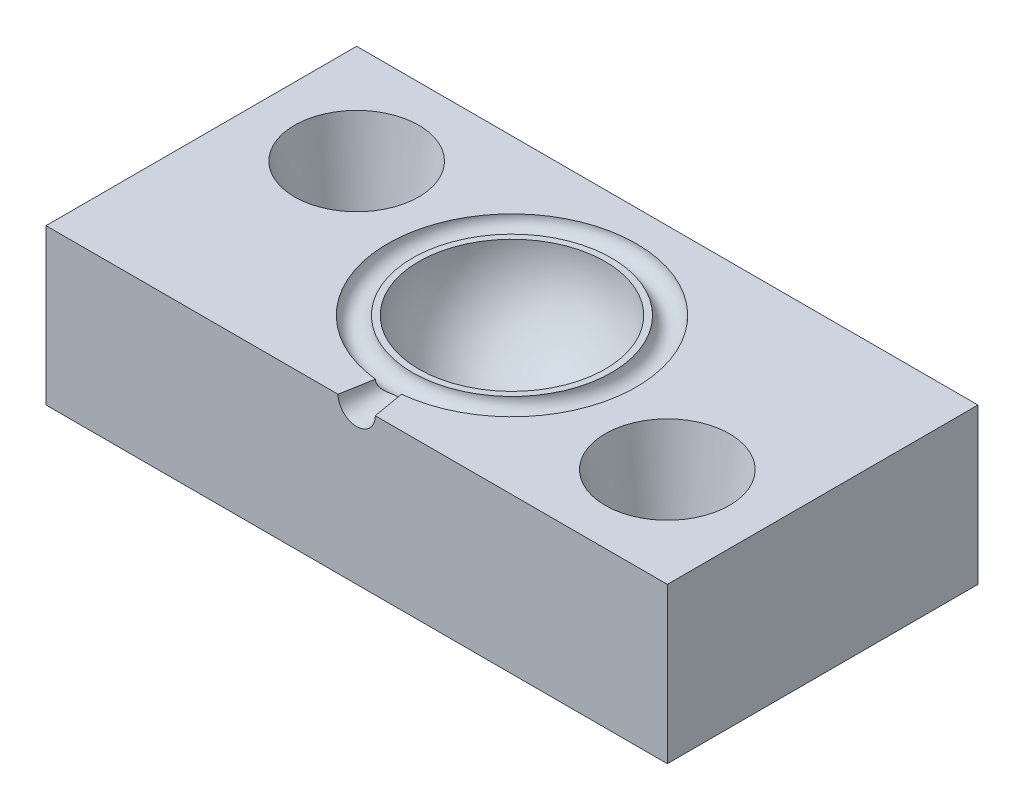
from build123d import *

# Parameters (mm, degrees)
ESQUISSE1_W                       = 50
ESQUISSE1_H                       = 25
BOSS_EXTRU_1_DEPTH                = 12.5
ESQUISSE2_R                       = 5
ENL_V_MAT_EXTRU_1_DEPTH           = 13.5
ENL_V_MAT_EXTRU_1_DRAFT           = -10
ENL_V_MAT_EXTRU_1_PROFILE_2_DEPTH = 13.5
ENL_V_MAT_EXTRU_1_PROFILE_2_DRAFT = -10
COQUE1_T                          = -3
ESQUISSE5_R                       = 1.5
ENL_V_MAT_EXTRU_2_DEPTH           = 4
ENL_V_MAT_EXTRU_2_DRAFT           = -10


with BuildPart() as part:
    # Esquisse1 → Boss.-Extru.1 (new body)
    with BuildSketch(Plane(origin=(0, 0, 0), x_dir=(1, 0, 0), z_dir=(0, 1, 0))):
        Rectangle(ESQUISSE1_W, ESQUISSE1_H)
    extrude(amount=BOSS_EXTRU_1_DEPTH)


with BuildPart() as enl_v_mat_extru_1_tool:
    # Esquisse2 → Enlèv. mat.-Extru.1 (with draft: the straight prism first)
    with BuildSketch(Plane(origin=(0, 12.5, 0), x_dir=(1, 0, 0), z_dir=(0, 1, 0))):
        with Locations((17, -4.5)):
            Circle(ESQUISSE2_R)
    extrude(amount=-ENL_V_MAT_EXTRU_1_DEPTH)
    # Enlèv. mat.-Extru.1: the draft: its side faces are tilted about the plane it starts from
    enl_v_mat_extru_1_sides = [enl_v_mat_extru_1_tool.faces().sort_by_distance(p)[0] for p in [
        (12, 5.75, 4.5),
    ]]
    draft(enl_v_mat_extru_1_sides, Plane(origin=(0, 12.5, 0), x_dir=(1, 0, 0), z_dir=(0, 1, 0)), ENL_V_MAT_EXTRU_1_DRAFT)


with BuildPart() as part_1:
    add(part.part)

    # Enlèv. mat.-Extru.1: cut by enl_v_mat_extru_1_tool
    add(enl_v_mat_extru_1_tool.part, mode=Mode.SUBTRACT)


with BuildPart() as enl_v_mat_extru_1_profile_2_tool:
    # Esquisse2 → Enlèv. mat.-Extru.1 profile 2 (with draft: the straight prism first)
    with BuildSketch(Plane(origin=(0, 12.5, 0), x_dir=(1, 0, 0), z_dir=(0, 1, 0))):
        with Locations((-17, 4.5)):
            Circle(ESQUISSE2_R)
    extrude(amount=-ENL_V_MAT_EXTRU_1_PROFILE_2_DEPTH)
    # Enlèv. mat.-Extru.1 profile 2: the draft: its side faces are tilted about the plane it starts from
    enl_v_mat_extru_1_profile_2_sides = [enl_v_mat_extru_1_profile_2_tool.faces().sort_by_distance(p)[0] for p in [
        (-22, 5.75, -4.5),
    ]]
    draft(enl_v_mat_extru_1_profile_2_sides, Plane(origin=(0, 12.5, 0), x_dir=(1, 0, 0), z_dir=(0, 1, 0)), ENL_V_MAT_EXTRU_1_PROFILE_2_DRAFT)


with BuildPart() as part_2:
    add(part_1.part)

    # Enlèv. mat.-Extru.1 profile 2: cut by enl_v_mat_extru_1_profile_2_tool
    add(enl_v_mat_extru_1_profile_2_tool.part, mode=Mode.SUBTRACT)

    # Esquisse3 → Enlèvement de matière-Révolution1 (revolve, cut)
    with BuildSketch(Plane.XY):
        with BuildLine():
            Line((0, 20), (0, 5))
            ThreePointArc((0, 5), (-7.5, 12.5), (0, 20))
        make_face()
    revolve(axis=Axis((0, 20, 0), (0, -1, 0)), mode=Mode.SUBTRACT)

    # Esquisse4 → Enlèvement de matière-Révolution3 (revolve, cut)
    with BuildSketch(Plane.XY, mode=Mode.PRIVATE) as enl_vement_de_mati_re_r_volution3_sk:
        with BuildLine():
            Line((8, 12.5), (10, 12.5))
            ThreePointArc((10, 12.5), (9, 11.5), (8, 12.5))
        make_face()
    revolve(enl_vement_de_mati_re_r_volution3_sk.sketch.rotate(Axis((0, 20, 0), (0, -1, 0)), 90), axis=Axis((0, 20, 0), (0, -1, 0)), mode=Mode.SUBTRACT)

    # Coque1
    coque1_openings = [part_2.faces().sort_by_distance(p)[0] for p in [
        (0, 0, 0),
    ]]
    offset(amount=COQUE1_T, openings=coque1_openings)


with BuildPart() as enl_v_mat_extru_2_tool:
    # Esquisse5 → Enlèv. mat.-Extru.2 (with draft: the straight prism first)
    with BuildSketch(Plane.XY.offset(12.5)):
        with Locations((0, 12.5)):
            Circle(ESQUISSE5_R)
    extrude(amount=-ENL_V_MAT_EXTRU_2_DEPTH)
    # Enlèv. mat.-Extru.2: the draft: its side faces are tilted about the plane it starts from
    enl_v_mat_extru_2_sides = [enl_v_mat_extru_2_tool.faces().sort_by_distance(p)[0] for p in [
        (-1.5, 12.5, 10.5),
    ]]
    draft(enl_v_mat_extru_2_sides, Plane.XY.offset(12.5), ENL_V_MAT_EXTRU_2_DRAFT)


with BuildPart() as part_3:
    add(part_2.part)

    # Enlèv. mat.-Extru.2: cut by enl_v_mat_extru_2_tool
    add(enl_v_mat_extru_2_tool.part, mode=Mode.SUBTRACT)


solid = part_3.part
